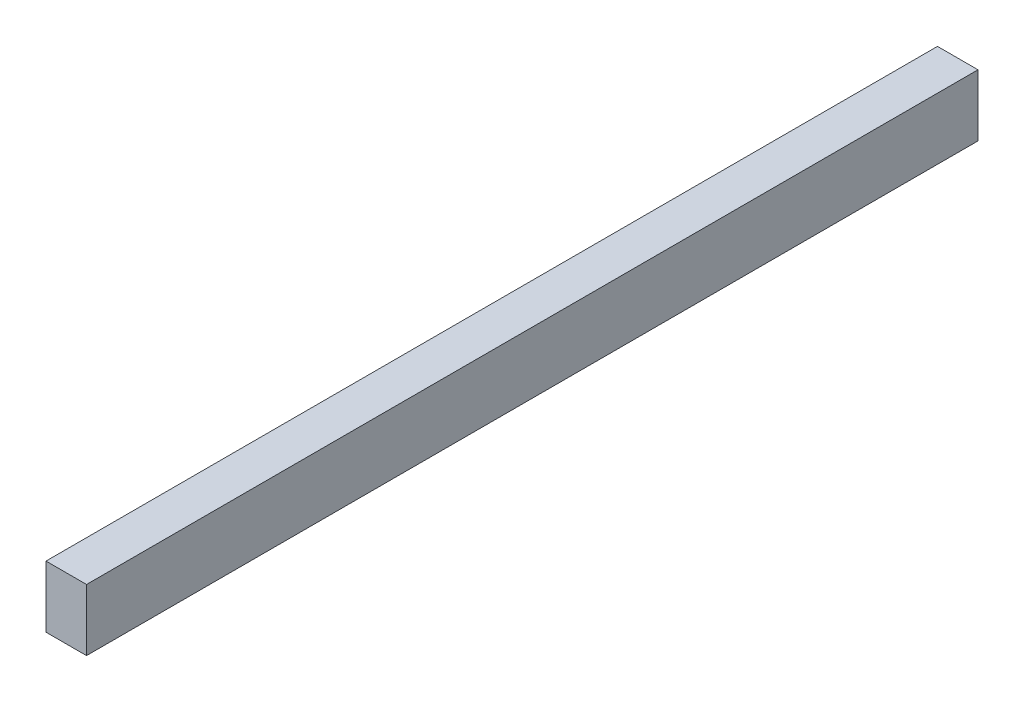
from build123d import *

# Parameters (mm, degrees)
SKETCH1_W           = 38.1
SKETCH1_H           = 57.94375
BOSS_EXTRUDE1_DEPTH = 838.2


with BuildPart() as part:
    # Sketch1 → Boss-Extrude1 (new body)
    with BuildSketch(Plane.XY):
        with Locations((-5.264778863, 20.17583873)):
            Rectangle(SKETCH1_W, SKETCH1_H)
    extrude(amount=BOSS_EXTRUDE1_DEPTH)


solid = part.part
